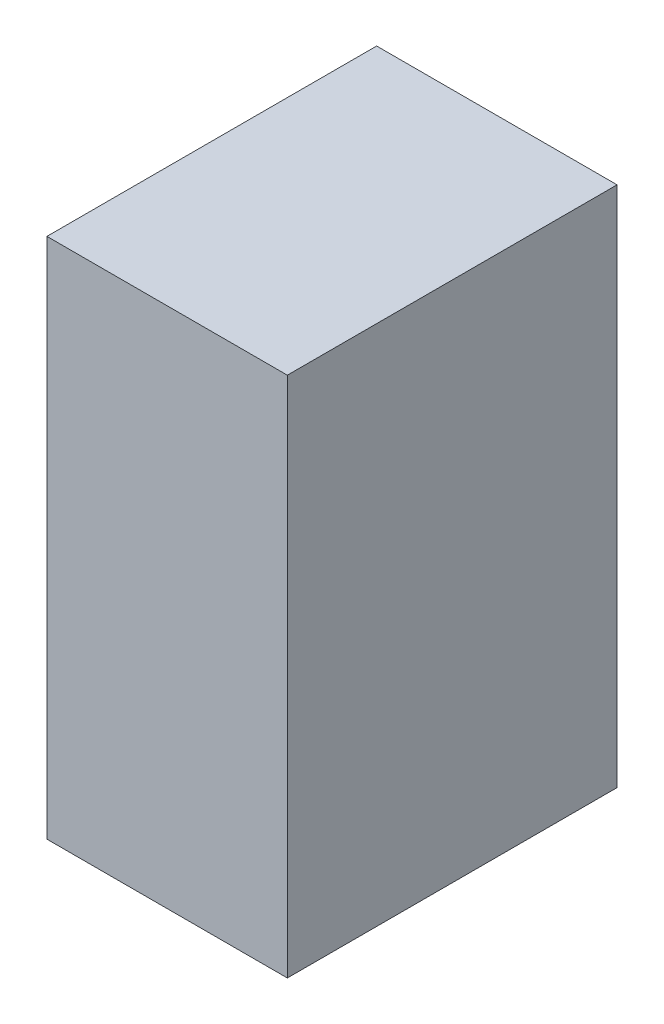
from build123d import *

# Parameters (mm, degrees)
CROQUIS1_W              = 35
CROQUIS1_H              = 48
SALIENTE_EXTRUIR1_DEPTH = 76


with BuildPart() as part:
    # Croquis1 → Saliente-Extruir1 (new body)
    with BuildSketch(Plane(origin=(0, 0, 0), x_dir=(1, 0, 0), z_dir=(0, 1, 0))):
        Rectangle(CROQUIS1_W, CROQUIS1_H)
    extrude(amount=SALIENTE_EXTRUIR1_DEPTH)


solid = part.part
